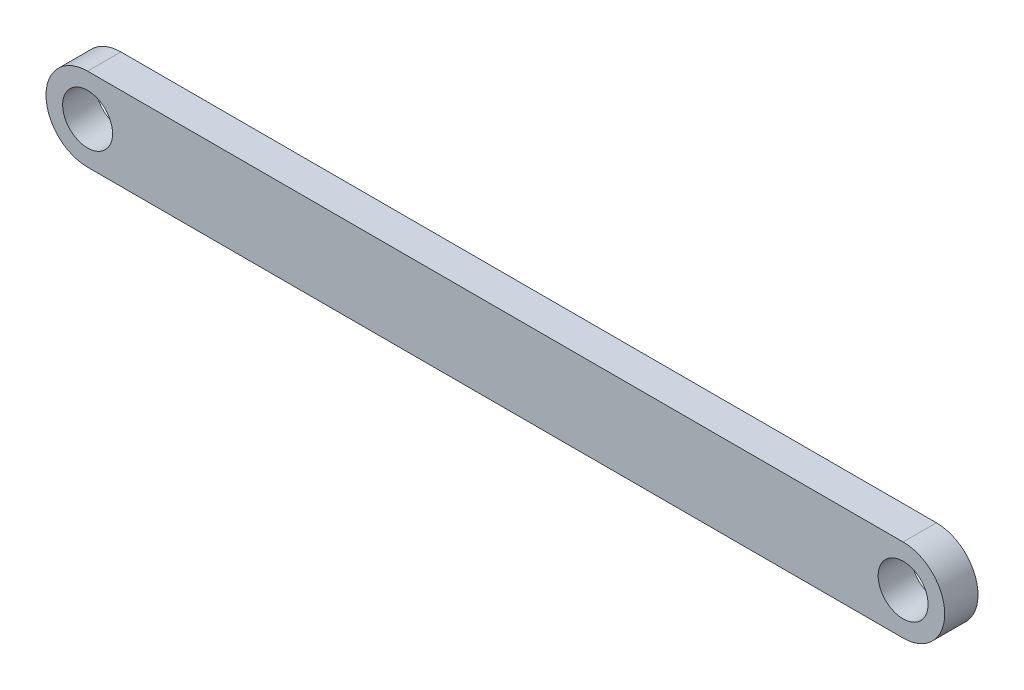
from build123d import *

# Parameters (mm, degrees)
SKETCH1_R           = 1.5
BOSS_EXTRUDE1_DEPTH = 2


with BuildPart() as part:
    # Sketch1 → Boss-Extrude1 (new body)
    with BuildSketch(Plane.XY):
        with BuildLine():
            Line((0.055761485, 2.332176341), (49.055761485, 2.332176341))
            ThreePointArc((49.055761485, 2.332176341), (51.555761485, -0.167823659), (49.055761485, -2.667823659))
            Line((49.055761485, -2.667823659), (0.055761485, -2.667823659))
            ThreePointArc((0.055761485, -2.667823659), (-2.444238515, -0.167823659), (0.055761485, 2.332176341))
        make_face()
        with Locations((0.055761485, -0.167823659)):
            Circle(SKETCH1_R, mode=Mode.SUBTRACT)
        with Locations((49.055761485, -0.167823659)):
            Circle(SKETCH1_R, mode=Mode.SUBTRACT)
    extrude(amount=BOSS_EXTRUDE1_DEPTH)


solid = part.part
